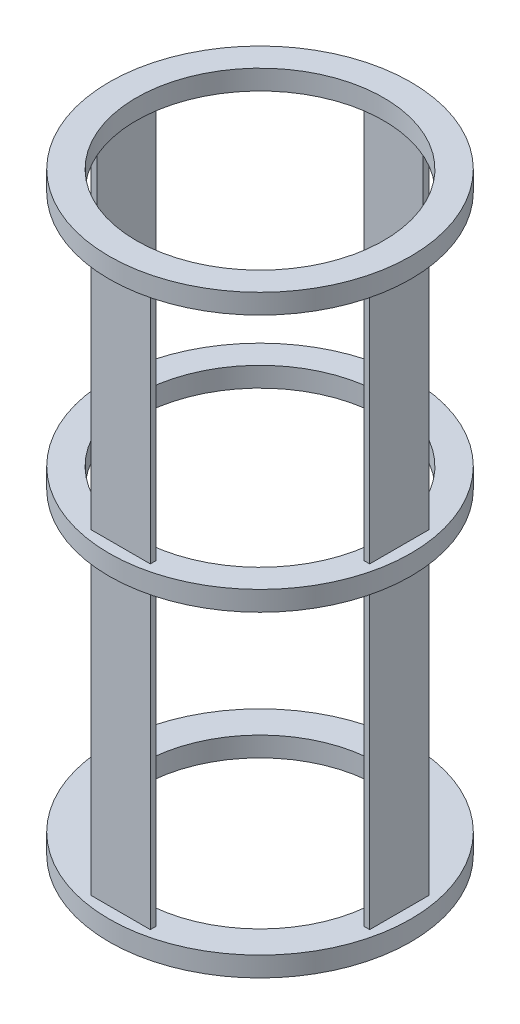
from build123d import *

# Parameters (mm, degrees)
ESQUISSE1_R                  = 76.2
ESQUISSE1_R_2                = 60
BOSS_EXTRU_1_DEPTH           = 10
ESQUISSE2_W                  = 30
ESQUISSE2_H                  = 3
BOSS_EXTRU_2_DEPTH           = 290
R_P_TITION_CIRCULAIRE1_COUNT = 4
ESQUISSE5_R                  = 76.2
ESQUISSE5_R_2                = 62.5
BOSS_EXTRU_3_DEPTH           = 10
R_P_TITION_LIN_AIRE2_COUNT   = 2
R_P_TITION_LIN_AIRE2_PITCH   = 130


with BuildPart() as part:
    # Esquisse1 → Boss.-Extru.1 (new body)
    with BuildSketch(Plane(origin=(0, 0, 0), x_dir=(1, 0, 0), z_dir=(0, 1, 0))):
        Circle(ESQUISSE1_R)
        Circle(ESQUISSE1_R_2, mode=Mode.SUBTRACT)
    extrude(amount=BOSS_EXTRU_1_DEPTH)

    # Esquisse2 → Boss.-Extru.2 (add)
    with BuildSketch(Plane(origin=(0, 10, 0), x_dir=(1, 0, 0), z_dir=(0, 1, 0))):
        with Locations((0, 68.920167566)):
            Rectangle(ESQUISSE2_W, ESQUISSE2_H)
    boss_extru_2 = extrude(amount=BOSS_EXTRU_2_DEPTH)

    # Répétition circulaire1: Boss.-Extru.2 ×4 about axis
    r_p_tition_circulaire1_axis = Axis((0, 0, 0), (0, 1, 0))
    for i in range(1, R_P_TITION_CIRCULAIRE1_COUNT):
        add(boss_extru_2.rotate(r_p_tition_circulaire1_axis, i * 360 / R_P_TITION_CIRCULAIRE1_COUNT))

    # Esquisse5 → Boss.-Extru.3 (add)
    with BuildSketch(Plane(origin=(0, 160, 0), x_dir=(1, 0, 0), z_dir=(0, 1, 0))):
        Circle(ESQUISSE5_R)
        Circle(ESQUISSE5_R_2, mode=Mode.SUBTRACT)
    boss_extru_3 = extrude(amount=BOSS_EXTRU_3_DEPTH)

    # Répétition linéaire2: Boss.-Extru.3 ×2
    with Locations(*[(0, i * R_P_TITION_LIN_AIRE2_PITCH, 0) for i in range(1, R_P_TITION_LIN_AIRE2_COUNT)]):
        add(boss_extru_3)


solid = part.part
